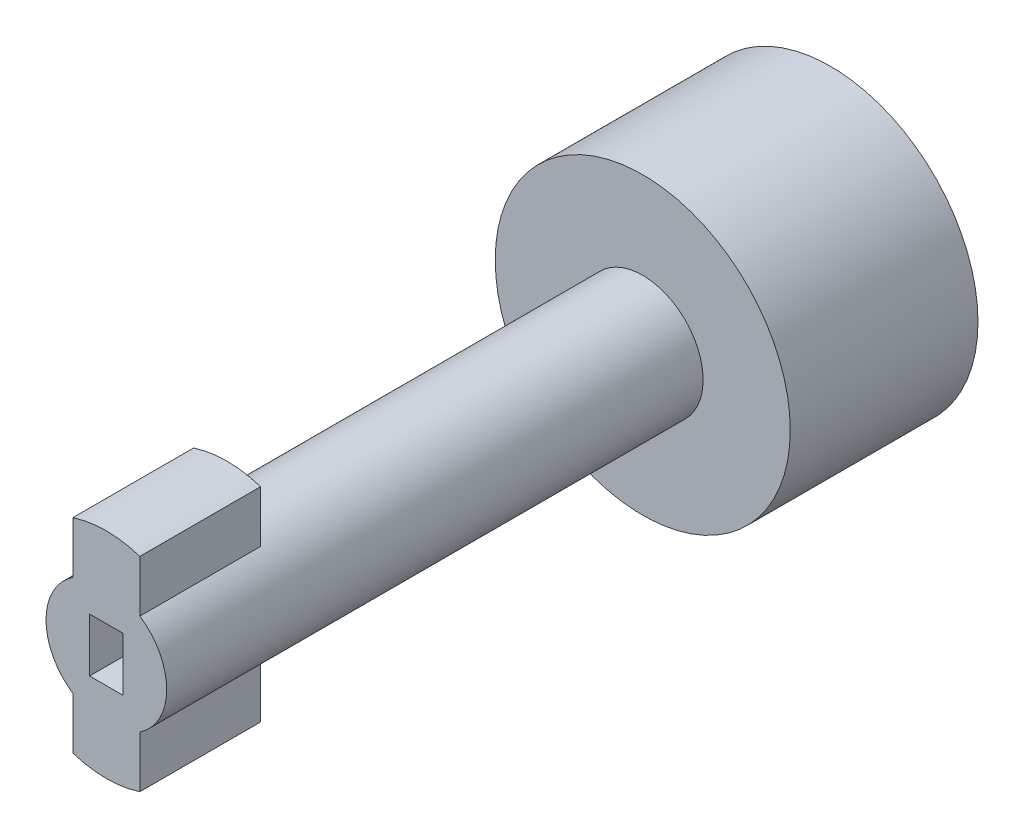
from build123d import *

# Parameters (mm, degrees)
CROQUIS1_R              = 4.5
SALIENTE_EXTRUIR1_DEPTH = 25
CROQUIS2_W              = 5
CROQUIS2_H              = 17
SALIENTE_EXTRUIR2_DEPTH = 9
CROQUIS3_R              = 11
CROQUIS3_R_2            = 8
CORTAR_EXTRUIR1_DEPTH   = 9
CROQUIS4_R              = 4.5
SALIENTE_EXTRUIR4_DEPTH = 2
CROQUIS6_W              = 2.5
CROQUIS6_H              = 4
CORTAR_EXTRUIR2_DEPTH   = 5
CROQUIS8_R              = 4.5
SALIENTE_EXTRUIR5_DEPTH = 13
CROQUIS9_R              = 11
SALIENTE_EXTRUIR6_DEPTH = 14


with BuildPart() as part:
    # Croquis1 → Saliente-Extruir1 (new body)
    with BuildSketch(Plane.XY):
        Circle(CROQUIS1_R)
    extrude(amount=SALIENTE_EXTRUIR1_DEPTH)

    # Croquis2 → Saliente-Extruir2 (add)
    with BuildSketch(Plane.XY.offset(25)):
        Rectangle(CROQUIS2_W, CROQUIS2_H)
    extrude(amount=-SALIENTE_EXTRUIR2_DEPTH)

    # Croquis3 → Cortar-Extruir1 (cut)
    with BuildSketch(Plane.XY.offset(25)):
        Circle(CROQUIS3_R)
        Circle(CROQUIS3_R_2, mode=Mode.SUBTRACT)
    extrude(amount=-CORTAR_EXTRUIR1_DEPTH, mode=Mode.SUBTRACT)

    # Croquis4 → Saliente-Extruir4 (add)
    with BuildSketch(Plane(origin=(0, 0, 0), x_dir=(-1, 0, 0), z_dir=(0, 0, -1))):
        Circle(CROQUIS4_R)
    extrude(amount=SALIENTE_EXTRUIR4_DEPTH)

    # Croquis6 → Cortar-Extruir2 (cut)
    with BuildSketch(Plane.XY.offset(25)):
        Rectangle(CROQUIS6_W, CROQUIS6_H)
    extrude(amount=-CORTAR_EXTRUIR2_DEPTH, mode=Mode.SUBTRACT)

    # Croquis8 → Saliente-Extruir5 (add)
    with BuildSketch(Plane(origin=(0, 0, -2), x_dir=(-1, 0, 0), z_dir=(0, 0, -1))):
        Circle(CROQUIS8_R)
    extrude(amount=SALIENTE_EXTRUIR5_DEPTH)

    # Croquis9 → Saliente-Extruir6 (add)
    with BuildSketch(Plane(origin=(0, 0, -15), x_dir=(-1, 0, 0), z_dir=(0, 0, -1))):
        Circle(CROQUIS9_R)
    extrude(amount=SALIENTE_EXTRUIR6_DEPTH)


solid = part.part
